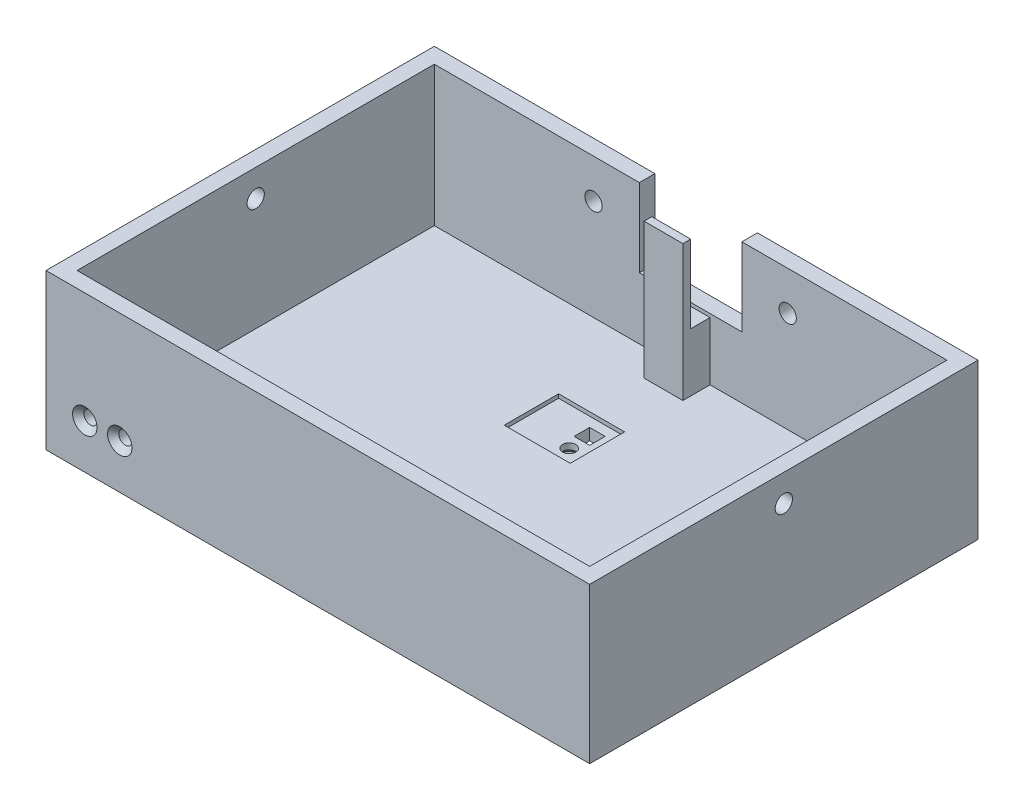
from build123d import *

# Parameters (mm, degrees)
SKETCH_1_W                  = 140
SKETCH_1_H                  = 100
SKETCH_1_W_2                = 132
SKETCH_1_H_2                = 92
EXTRUDE_2_DEPTH             = 4
EXTRUDE_3_DEPTH             = 2
EXTRUDE_START               = 4
SKETCH_1_6_W                = 140
SKETCH_1_6_H                = 100
SKETCH_1_6_W_2              = 132
SKETCH_1_6_H_2              = 92
EXTRUDE_4_DEPTH             = 36
HOLE_WIZARD_M31_D           = 3.4
HOLE_WIZARD_M31_DEPTH       = 4
HOLE_WIZARD_M31_CSINK_D     = 6.3
HOLE_WIZARD_M31_CSINK_ANGLE = 90
CUT_EXTRUDE_1_REACH         = 155.948
SKETCH_6_R                  = 2.225
CUT_EXTRUDE_3_REACH         = 130.452
SKETCH_7_W                  = 26.4
SKETCH_7_H                  = 20.1
CUT_EXTRUDE_6_REACH         = 130.452
SKETCH_7_9_R                = 2.225
HOLE_WIZARD_M33_D           = 3.4
HOLE_WIZARD_M33_CSINK_D     = 6.3
HOLE_WIZARD_M33_CSINK_ANGLE = 90
CUT_EXTRUDE_8_REACH         = 96.868
SKETCH_15_W                 = 4
SKETCH_15_H                 = 4
CUT_EXTRUDE_9_REACH         = 99.868
CUT_EXTRUDE_START           = -3
SKETCH_15_4_W               = 17
SKETCH_15_4_H               = 14
SKETCH_15_4_W_2             = 4
SKETCH_15_4_H_2             = 4
EXTRUDE_START_2             = -4
SKETCH_20_W                 = 10
SKETCH_20_H                 = 5
SKETCH_20_H_2               = 2
EXTRUDE_7_DEPTH             = 15
EXTRUDE_START_3             = -39
SKETCH_20_3_W               = 10
SKETCH_20_3_H               = 2
EXTRUDE_8_DEPTH             = 20
SKETCH_21_W                 = 0.664850428
SKETCH_21_H                 = 3.704166666
CUT_EXTRUDE_10_DEPTH        = 1


with BuildPart() as part:
    # Эскиз1 → Бобышка-Вытянуть2 (new body)
    with BuildSketch(Plane(origin=(0, 0, 0), x_dir=(1, 0, 0), z_dir=(0, 1, 0))):
        Rectangle(SKETCH_1_W, SKETCH_1_H)
        Rectangle(SKETCH_1_W_2, SKETCH_1_H_2, mode=Mode.SUBTRACT)
        Polygon((66, -46), (66, 46), (-66, 46), (-66, -46), (-63, -46), (-63, -44.5), (-59.5, -44.5), (-59.5, -41.9), (-51.5, -41.9), (-51.5, -44.5), (-48, -44.5), (-48, -46), align=None)
    extrude(amount=EXTRUDE_2_DEPTH)

    # Эскиз1<5> → Бобышка-Вытянуть3 (add)
    with BuildSketch(Plane(origin=(0, 0, 0), x_dir=(1, 0, 0), z_dir=(0, 1, 0))):
        Polygon((-63, -46), (-48, -46), (-48, -44.5), (-51.5, -44.5), (-51.5, -44.6), (-59.5, -44.6), (-59.5, -44.5), (-63, -44.5), align=None)
    extrude(amount=EXTRUDE_3_DEPTH)

    # Эскиз1<6> → Бобышка-Вытянуть4 (add)
    with BuildSketch(Plane(origin=(0, 0, 0), x_dir=(1, 0, 0), z_dir=(0, 1, 0)).offset(EXTRUDE_START)):
        Rectangle(SKETCH_1_6_W, SKETCH_1_6_H)
        Rectangle(SKETCH_1_6_W_2, SKETCH_1_6_H_2, mode=Mode.SUBTRACT)
    extrude(amount=EXTRUDE_4_DEPTH)

    # Зенковка для винта с потайной головкой M31
    with Locations(Plane(origin=(-51, 11.5, 50), x_dir=(1, 0, 0), z_dir=(0, 0, 1))):
        with Locations((0, 0), (-9, 0)):
            CounterSinkHole(HOLE_WIZARD_M31_D / 2, HOLE_WIZARD_M31_CSINK_D / 2, depth=HOLE_WIZARD_M31_DEPTH, counter_sink_angle=HOLE_WIZARD_M31_CSINK_ANGLE)

    # Эскиз6 → Вырез-Вытянуть1 (cut, up to next)
    with BuildSketch(Plane(origin=(70, 0, 0), x_dir=(0, 0, -1), z_dir=(1, 0, 0)), mode=Mode.PRIVATE) as cut_extrude_1_sk1:
        with Locations((0, 33)):
            Circle(SKETCH_6_R)
    cut_extrude_1_tool1 = extrude(cut_extrude_1_sk1.sketch, amount=-CUT_EXTRUDE_1_REACH, mode=Mode.PRIVATE) & part.part
    cut_extrude_1 = cut_extrude_1_tool1.solids().sort_by_distance((70, 33, 0))[0]
    add(cut_extrude_1, mode=Mode.SUBTRACT)

    # Зеркальное отражение1: Вырез-Вытянуть1 across plane
    add(cut_extrude_1.mirror(Plane(origin=(0, 0, 0), x_dir=(0, 0, 1), z_dir=(1, 0, 0))), mode=Mode.SUBTRACT)

    # Эскиз7 → Вырез-Вытянуть3 (cut, up to next)
    with BuildSketch(Plane(origin=(0, 0, -50), x_dir=(-1, 0, 0), z_dir=(0, 0, -1)), mode=Mode.PRIVATE) as cut_extrude_3_sk1:
        with Locations((0, 29.95)):
            Rectangle(SKETCH_7_W, SKETCH_7_H)
    cut_extrude_3_tool1 = extrude(cut_extrude_3_sk1.sketch, amount=-CUT_EXTRUDE_3_REACH, mode=Mode.PRIVATE) & part.part
    add(cut_extrude_3_tool1.solids().sort_by_distance((0, 29.95, -50))[0], mode=Mode.SUBTRACT)

    # Эскиз7<9> → Вырез-Вытянуть6 (cut, up to next)
    with BuildSketch(Plane(origin=(0, 0, -50), x_dir=(-1, 0, 0), z_dir=(0, 0, -1)), mode=Mode.PRIVATE) as cut_extrude_6_sk1:
        with Locations((-25, 29.95)):
            Circle(SKETCH_7_9_R)
    cut_extrude_6_tool1 = extrude(cut_extrude_6_sk1.sketch, amount=-CUT_EXTRUDE_6_REACH, mode=Mode.PRIVATE) & part.part
    # Эскиз7<9> → Вырез-Вытянуть6 (cut, up to next)
    with BuildSketch(Plane(origin=(0, 0, -50), x_dir=(-1, 0, 0), z_dir=(0, 0, -1)), mode=Mode.PRIVATE) as cut_extrude_6_sk2:
        with Locations((25, 29.95)):
            Circle(SKETCH_7_9_R)
    cut_extrude_6_tool2 = extrude(cut_extrude_6_sk2.sketch, amount=-CUT_EXTRUDE_6_REACH, mode=Mode.PRIVATE) & part.part
    add(cut_extrude_6_tool1.solids().sort_by_distance((25, 29.95, -50))[0], mode=Mode.SUBTRACT)
    add(cut_extrude_6_tool2.solids().sort_by_distance((-25, 29.95, -50))[0], mode=Mode.SUBTRACT)

    # Зенковка для винта с потайной головкой M33 (through all)
    with Locations(Plane(origin=(0, 0, -14.7), x_dir=(0, 0, -1), z_dir=(0, -1, 0))):
        with Locations((0, 0)):
            CounterSinkHole(HOLE_WIZARD_M33_D / 2, HOLE_WIZARD_M33_CSINK_D / 2, counter_sink_angle=HOLE_WIZARD_M33_CSINK_ANGLE)

    # Эскиз15 → Вырез-Вытянуть8 (cut, up to next)
    with BuildSketch(Plane.XZ, mode=Mode.PRIVATE) as cut_extrude_8_sk1:
        with Locations((0, -20)):
            Rectangle(SKETCH_15_W, SKETCH_15_H)
    cut_extrude_8_tool1 = extrude(cut_extrude_8_sk1.sketch, amount=-CUT_EXTRUDE_8_REACH, mode=Mode.PRIVATE) & part.part
    add(cut_extrude_8_tool1.solids().sort_by_distance((0, 0, -20))[0], mode=Mode.SUBTRACT)

    # Эскиз15<4> → Вырез-Вытянуть9 (cut, up to next)
    with BuildSketch(Plane.XZ.offset(CUT_EXTRUDE_START), mode=Mode.PRIVATE) as cut_extrude_9_sk1:
        with Locations((-4, -17.5)):
            Rectangle(SKETCH_15_4_W, SKETCH_15_4_H)
        with Locations((0, -20)):
            Rectangle(SKETCH_15_4_W_2, SKETCH_15_4_H_2, mode=Mode.SUBTRACT)
    cut_extrude_9_tool1 = extrude(cut_extrude_9_sk1.sketch, amount=-CUT_EXTRUDE_9_REACH, mode=Mode.PRIVATE) & part.part
    add(cut_extrude_9_tool1.solids().sort_by_distance((-4.288288, 3, -17.31982))[0], mode=Mode.SUBTRACT)

    # Эскиз20 → Бобышка-Вытянуть7 (add)
    with BuildSketch(Plane.XZ.offset(EXTRUDE_START_2)):
        with Locations((0, -43.5)):
            Rectangle(SKETCH_20_W, SKETCH_20_H)
        with Locations((0, -40)):
            Rectangle(SKETCH_20_W, SKETCH_20_H_2)
    extrude(amount=-EXTRUDE_7_DEPTH)

    # Эскиз20<3> → Бобышка-Вытянуть8 (add)
    with BuildSketch(Plane.XZ.offset(EXTRUDE_START_3)):
        with Locations((0, -40)):
            Rectangle(SKETCH_20_3_W, SKETCH_20_3_H)
    extrude(amount=EXTRUDE_8_DEPTH)

    # Эскиз21 → Вырез-Вытянуть10 (cut)
    with BuildSketch(Plane.XZ):
        Polygon((-7.360844017, 26.295833333), (-8.100638522, 26.295833333), (-8.761778846, 27.595111345), (-9.422919171, 26.295833333), (-10.162713675, 26.295833333), (-9.09420406, 28.395751536), (-9.09420406, 30), (-8.429353632, 30), (-8.429353632, 28.395751536), align=None)
        with BuildLine():
            Line((-4.67769765, 30), (-4.67769765, 26.295833333))
            Line((-4.67769765, 26.295833333), (-5.271314103, 26.295833333))
            add(Edge.make_bspline(
                [(-5.271314103, 26.295833333), (-5.31287104, 26.29582766), (-5.393282926, 26.295816683), (-5.509295092, 26.299903172), (-5.616644377, 26.305119252), (-5.715461788, 26.311150817), (-5.805710741, 26.321160915), (-5.887453392, 26.331933671), (-5.960386991, 26.344839118), (-6.005477322, 26.356423188), (-6.026691039, 26.361873164)],
                knots=[0, 0, 0, 0, 1.311970222, 2.538637508, 3.664491357, 4.705491327, 5.663608299, 6.530571107, 7.308675535, 8, 8, 8, 8], degree=3))
            add(Edge.make_bspline(
                [(-6.026691039, 26.361873164), (-6.054546615, 26.369560182), (-6.109208197, 26.384644579), (-6.187505155, 26.415102656), (-6.261764836, 26.448979565), (-6.331971001, 26.48755156), (-6.397293339, 26.531538006), (-6.458627281, 26.580099943), (-6.515687524, 26.633253783), (-6.567564548, 26.691314468), (-6.614388963, 26.752752651), (-6.655239972, 26.817596967), (-6.690526167, 26.884819689), (-6.717620988, 26.955580973), (-6.740373771, 27.028032846), (-6.755595868, 27.103646953), (-6.765809559, 27.181771929), (-6.766750122, 27.234950154), (-6.767227564, 27.261944111)],
                knots=[0, 0, 0, 0, 1.099879008, 2.158315707, 3.195196496, 4.207130292, 5.205157476, 6.190838564, 7.183874245, 8.171129509, 9.152705923, 10.122275948, 11.08707516, 12.038677937, 13.004120747, 13.975884785, 14.972532894, 16, 16, 16, 16], degree=3))
            add(Edge.make_bspline(
                [(-6.767227564, 27.261944111), (-6.76606929, 27.296642989), (-6.763788001, 27.364984441), (-6.746281055, 27.464900878), (-6.718067585, 27.559857826), (-6.67819946, 27.650677442), (-6.624678653, 27.737222193), (-6.557936859, 27.821133851), (-6.476313973, 27.901266692), (-6.414743342, 27.950351077), (-6.382860911, 27.975767895)],
                knots=[0, 0, 0, 0, 0.986462413, 1.942894939, 2.875435142, 3.798266677, 4.755009598, 5.761362919, 6.840791609, 8, 8, 8, 8], degree=3))
            add(Edge.make_bspline(
                [(-6.382860911, 27.975767895), (-6.408979822, 27.989097155), (-6.460191781, 28.015232146), (-6.532852683, 28.058239537), (-6.600297973, 28.103797407), (-6.662059563, 28.151835509), (-6.719599834, 28.201400191), (-6.769346127, 28.255527376), (-6.816213212, 28.310039174), (-6.856337282, 28.368448582), (-6.891028514, 28.42950758), (-6.921804296, 28.492525813), (-6.946942144, 28.558756422), (-6.968581336, 28.627252077), (-6.984979225, 28.698720449), (-6.995584602, 28.772715956), (-7.003720801, 28.849195216), (-7.004352804, 28.901291794), (-7.004674145, 28.927780282)],
                knots=[0, 0, 0, 0, 1.164301211, 2.282872552, 3.350830854, 4.394111106, 5.389302619, 6.362088852, 7.310365691, 8.24222091, 9.170601078, 10.097577168, 11.024240953, 11.981127157, 12.948542686, 13.932080445, 14.948567018, 16, 16, 16, 16], degree=3))
            add(Edge.make_bspline(
                [(-7.004674145, 28.927780282), (-7.002692802, 28.978397696), (-6.998780658, 29.078341299), (-6.96712433, 29.224518762), (-6.916596092, 29.36381475), (-6.84574944, 29.493996255), (-6.759425249, 29.61275297), (-6.660581223, 29.717639041), (-6.549120308, 29.805474765), (-6.446974469, 29.865364426), (-6.358155382, 29.905297616), (-6.284285354, 29.929765961), (-6.20499898, 29.952445355), (-6.119408383, 29.970015998), (-6.027940433, 29.983108035), (-5.930636934, 29.992646338), (-5.827162295, 29.99866195), (-5.756109363, 29.999544966), (-5.719494525, 30)],
                knots=[0, 0, 0, 0, 1.284225818, 2.535691644, 3.779474941, 5.035581115, 6.285533147, 7.498311102, 8.683187976, 9.876672238, 10.49522506, 11.152635743, 11.850557634, 12.588370465, 13.369094102, 14.195874568, 15.07030211, 16, 16, 16, 16], degree=3))
            Line((-5.719494525, 30), (-4.67769765, 30))
        make_face()
        with BuildLine():
            Line((-5.342548077, 26.960683761), (-5.342548077, 27.768002137))
            Line((-5.342548077, 27.768002137), (-5.519148972, 27.768002137))
            add(Edge.make_bspline(
                [(-5.519148972, 27.768002137), (-5.543150918, 27.767793787), (-5.589485222, 27.767391581), (-5.656405391, 27.762174814), (-5.718647736, 27.753340305), (-5.776129913, 27.740752532), (-5.829187703, 27.725499305), (-5.877192725, 27.70609866), (-5.920300863, 27.682950654), (-5.97109283, 27.649311019), (-6.023411598, 27.597796057), (-6.070260271, 27.525078967), (-6.097716924, 27.440911558), (-6.100790162, 27.381609366), (-6.102377137, 27.350986579)],
                knots=[0, 0, 0, 0, 1.06517797, 2.056261606, 2.976983468, 3.853439442, 4.666321732, 5.424739265, 6.146762548, 6.834937974, 8.123729748, 9.372478121, 10.64318598, 12, 12, 12, 12], degree=3))
            add(Edge.make_bspline(
                [(-6.102377137, 27.350986579), (-6.101107736, 27.322301724), (-6.0986534, 27.266840711), (-6.07098899, 27.188915267), (-6.02789325, 27.120216444), (-5.977780501, 27.072519042), (-5.92999461, 27.040450445), (-5.888860674, 27.019067359), (-5.843656126, 27.000080932), (-5.793272027, 26.986822794), (-5.739218145, 26.974378655), (-5.680330231, 26.966811946), (-5.617204196, 26.961226635), (-5.57357826, 26.9608686), (-5.551055856, 26.960683761)],
                knots=[0, 0, 0, 0, 1.347812291, 2.605940898, 3.848830773, 5.144272192, 5.83350599, 6.558918059, 7.32804622, 8.140548749, 9.012446266, 9.943019774, 10.938059685, 12, 12, 12, 12], degree=3))
            Line((-5.551055856, 26.960683761), (-5.342548077, 26.960683761))
        make_face(mode=Mode.SUBTRACT)
        with BuildLine():
            Line((-5.342548077, 28.385363248), (-5.342548077, 29.335149573))
            Line((-5.342548077, 29.335149573), (-5.533989383, 29.335149573))
            add(Edge.make_bspline(
                [(-5.533989383, 29.335149573), (-5.571836642, 29.334929454), (-5.644602721, 29.334506248), (-5.748854794, 29.329534528), (-5.843594627, 29.320313304), (-5.928844514, 29.309547079), (-6.003906665, 29.292523899), (-6.070151968, 29.274824174), (-6.1264325, 29.252057352), (-6.17370873, 29.225655995), (-6.213247633, 29.195791329), (-6.247485595, 29.163470084), (-6.276042616, 29.127354439), (-6.299008818, 29.08824331), (-6.31830134, 29.046497592), (-6.330119516, 29.000731595), (-6.339075358, 28.952368581), (-6.339570425, 28.918921985), (-6.339823718, 28.901809562)],
                knots=[0, 0, 0, 0, 1.753677247, 3.371663338, 4.833688836, 6.164395063, 7.349095089, 8.3975697, 9.338276771, 10.154261968, 10.899224605, 11.628775934, 12.330426574, 13.024264642, 13.727131073, 14.452891561, 15.208446408, 16, 16, 16, 16], degree=3))
            add(Edge.make_bspline(
                [(-6.339823718, 28.901809562), (-6.339267862, 28.88224015), (-6.338185204, 28.844124201), (-6.329314979, 28.78842355), (-6.31326656, 28.73638578), (-6.292737226, 28.686661361), (-6.265021063, 28.640606417), (-6.231164445, 28.597914337), (-6.191468328, 28.558459282), (-6.145807334, 28.521643116), (-6.092791868, 28.488572661), (-6.031202431, 28.461825413), (-5.962630199, 28.437695864), (-5.885732735, 28.419043462), (-5.801112201, 28.403045041), (-5.708035099, 28.393532236), (-5.607311669, 28.386443148), (-5.537466849, 28.385731394), (-5.501340478, 28.385363248)],
                knots=[0, 0, 0, 0, 0.844862234, 1.645564352, 2.426138401, 3.19188377, 3.963047654, 4.738710309, 5.53926994, 6.37496817, 7.267116735, 8.227971149, 9.268346748, 10.402975021, 11.641070045, 12.984514716, 14.440277492, 16, 16, 16, 16], degree=3))
            Line((-5.501340478, 28.385363248), (-5.342548077, 28.385363248))
        make_face(mode=Mode.SUBTRACT)
        Polygon((-0.593616453, 26.295833333), (-2.588167735, 26.295833333), (-2.588167735, 26.960683761), (-1.25846688, 26.960683761), (-1.25846688, 27.673023504), (-2.588167735, 27.673023504), (-2.588167735, 28.337873932), (-1.25846688, 28.337873932), (-1.25846688, 29.335149573), (-2.588167735, 29.335149573), (-2.588167735, 30), (-0.593616453, 30), align=None)
        with BuildLine():
            Line((3.015571581, 26.295833333), (2.177830362, 26.295833333))
            add(Edge.make_bspline(
                [(2.177830362, 26.295833333), (2.112517208, 26.296279346), (1.986266142, 26.297141494), (1.803379182, 26.30722713), (1.633190412, 26.322037433), (1.476084825, 26.344703935), (1.331496675, 26.371011955), (1.200493246, 26.406243982), (1.082008378, 26.446675766), (0.974798578, 26.493784373), (0.877193779, 26.549031863), (0.785172007, 26.611100127), (0.697670919, 26.680920335), (0.614205601, 26.758655019), (0.534572647, 26.843787324), (0.460641374, 26.938031461), (0.390041599, 27.03894638), (0.323918809, 27.146882332), (0.265061267, 27.261626225), (0.212671457, 27.381372071), (0.169021282, 27.506197699), (0.13347976, 27.635930755), (0.105168974, 27.770195435), (0.085355478, 27.909247561), (0.073107843, 28.052962573), (0.07186533, 28.150365134), (0.071233974, 28.199858106)],
                knots=[0, 0, 0, 0, 1.44349102, 2.790284463, 4.047513061, 5.218094321, 6.297837468, 7.293772999, 8.213586047, 9.062895527, 9.878013142, 10.689252941, 11.514048747, 12.349645483, 13.208421871, 14.087867281, 14.994836234, 15.929653487, 16.883274053, 17.843080533, 18.816554169, 19.803369425, 20.81449504, 21.847452076, 22.906230055, 24, 24, 24, 24], degree=3))
            add(Edge.make_bspline(
                [(0.071233974, 28.199858106), (0.072887037, 28.269696003), (0.076141188, 28.407175991), (0.103555301, 28.608925044), (0.147885975, 28.802326415), (0.210244162, 28.985844916), (0.287464039, 29.157926595), (0.379944374, 29.315124356), (0.485028616, 29.457758629), (0.603649263, 29.583462816), (0.731883678, 29.69216878), (0.865667065, 29.784182979), (1.004879735, 29.858041143), (1.127803931, 29.904163618), (1.234694759, 29.933151783), (1.328404927, 29.949991966), (1.435055199, 29.965610546), (1.555047536, 29.979035128), (1.688737769, 29.988228315), (1.83571191, 29.994576859), (1.996005557, 29.999294231), (2.107334607, 29.999758579), (2.165216012, 30)],
                knots=[0, 0, 0, 0, 1.315347898, 2.589339334, 3.828278609, 5.048487211, 6.235212834, 7.375728391, 8.47833097, 9.56625089, 10.624194351, 11.640157642, 12.619895326, 13.585848527, 14.106971868, 14.704705962, 15.37825295, 16.137840974, 16.978850452, 17.902510282, 18.909488129, 20, 20, 20, 20], degree=3))
            Line((2.165216012, 30), (3.015571581, 30))
            Line((3.015571581, 30), (3.015571581, 26.295833333))
        make_face()
        with BuildLine():
            Line((2.350721154, 26.960683761), (2.350721154, 29.335149573))
            Line((2.350721154, 29.335149573), (2.003455529, 29.335149573))
            add(Edge.make_bspline(
                [(2.003455529, 29.335149573), (1.962143416, 29.334949523), (1.882698503, 29.334564818), (1.767857898, 29.329279022), (1.661875638, 29.320695518), (1.564612902, 29.307999222), (1.47584609, 29.292722328), (1.395898998, 29.273826825), (1.324614054, 29.250848453), (1.26140341, 29.22376821), (1.203693487, 29.192850105), (1.150229912, 29.156747291), (1.098631039, 29.116625617), (1.049850562, 29.071341384), (1.003706716, 29.021484388), (0.96047237, 28.966800313), (0.919567981, 28.907455897), (0.882054014, 28.843135016), (0.847741196, 28.774526831), (0.817426711, 28.702257198), (0.791835736, 28.625932135), (0.772401883, 28.545585428), (0.755846802, 28.461715662), (0.743892763, 28.37378358), (0.737380162, 28.282076463), (0.736520533, 28.219655142), (0.736084402, 28.187985777)],
                knots=[0, 0, 0, 0, 1.502729547, 2.8898115, 4.181010027, 5.369596896, 6.45687185, 7.456390247, 8.355533714, 9.177830239, 9.954819978, 10.733423081, 11.521791071, 12.330436719, 13.151797389, 13.990712567, 14.864234656, 15.771624029, 16.697123225, 17.652960569, 18.620374037, 19.622036587, 20.657870943, 21.729319508, 22.8479736, 24, 24, 24, 24], degree=3))
            add(Edge.make_bspline(
                [(0.736084402, 28.187985777), (0.736967187, 28.13945709), (0.73868855, 28.044829909), (0.75539277, 27.907021755), (0.782308144, 27.777417158), (0.821516404, 27.656349058), (0.869732311, 27.543047772), (0.931039844, 27.438973329), (1.001714565, 27.342419836), (1.057634518, 27.285788843), (1.085576088, 27.257491987)],
                knots=[0, 0, 0, 0, 1.138242922, 2.219485503, 3.251901297, 4.239342788, 5.201071, 6.134757343, 7.067992642, 8, 8, 8, 8], degree=3))
            add(Edge.make_bspline(
                [(1.085576088, 27.257491987), (1.113126827, 27.233378423), (1.169396092, 27.184129198), (1.268186429, 27.125116032), (1.377048264, 27.073267181), (1.49847203, 27.032156824), (1.631284219, 26.999645002), (1.776275864, 26.977222393), (1.932670503, 26.962813862), (2.041017064, 26.961409006), (2.09695012, 26.960683761)],
                knots=[0, 0, 0, 0, 0.813307809, 1.661089106, 2.549956539, 3.493439533, 4.508053171, 5.589449661, 6.755572447, 8, 8, 8, 8], degree=3))
            Line((2.09695012, 26.960683761), (2.350721154, 26.960683761))
        make_face(mode=Mode.SUBTRACT)
        Polygon((5.67423127, 26.295833333), (5.057612179, 26.295833333), (3.561698718, 30), (4.2718124, 30), (4.55971638, 29.24017094), (6.173611111, 29.24017094), (6.461515091, 30), (7.170886752, 30), align=None)
        Polygon((5.366292735, 27.289398872), (5.921324119, 28.575320513), (4.811261351, 28.575320513), align=None, mode=Mode.SUBTRACT)
        Polygon((11.128082432, 26.295833333), (10.438003305, 26.295833333), (9.59284188, 28.879548945), (8.741744291, 26.295833333), (8.058343349, 26.295833333), (7.432077991, 30), (8.105090645, 30), (8.500587607, 27.660409155), (9.270804955, 30), (9.919330929, 30), (10.685096154, 27.660409155), (11.079851095, 30), (11.753605769, 30), align=None)
        with Locations((-24.789423077, 35.369017094)):
            Rectangle(SKETCH_21_W, SKETCH_21_H)
        Polygon((-21.892574786, 33.516933761), (-23.887126068, 33.516933761), (-23.887126068, 34.181784188), (-22.557425214, 34.181784188), (-22.557425214, 34.894123932), (-23.887126068, 34.894123932), (-23.887126068, 35.558974359), (-22.557425214, 35.558974359), (-22.557425214, 36.55625), (-23.887126068, 36.55625), (-23.887126068, 37.221100427), (-21.892574786, 37.221100427), align=None)
        Polygon((-17.579209235, 33.516933761), (-18.269288361, 33.516933761), (-19.114449786, 36.100649372), (-19.965547376, 33.516933761), (-20.648948317, 33.516933761), (-21.275213675, 37.221100427), (-20.602201022, 37.221100427), (-20.20670406, 34.881509582), (-19.436486712, 37.221100427), (-18.787960737, 37.221100427), (-18.022195513, 34.881509582), (-17.627440572, 37.221100427), (-16.953685897, 37.221100427), align=None)
        with BuildLine():
            add(Edge.make_bspline(
                [(-14.705363582, 33.421955128), (-14.76976538, 33.423621928), (-14.896909117, 33.426912568), (-15.083886107, 33.454363303), (-15.264094619, 33.499038862), (-15.437560483, 33.561398748), (-15.603692097, 33.642160392), (-15.763099871, 33.740220734), (-15.915346963, 33.856411855), (-16.058658326, 33.989075704), (-16.190071338, 34.134139472), (-16.305584868, 34.288798347), (-16.403641213, 34.451455541), (-16.483233785, 34.622142746), (-16.545389843, 34.800625505), (-16.588587573, 34.986971553), (-16.616440445, 35.180942266), (-16.619636403, 35.313021049), (-16.621260684, 35.380147403)],
                knots=[0, 0, 0, 0, 1.014151002, 2.002163778, 2.969868608, 3.93493411, 4.9003771, 5.874719092, 6.87846472, 7.912488755, 8.947011879, 9.957751389, 10.948740761, 11.933621513, 12.919426746, 13.920294397, 14.943031967, 16, 16, 16, 16], degree=3))
            add(Edge.make_bspline(
                [(-16.621260684, 35.380147403), (-16.619530349, 35.446517269), (-16.616120669, 35.57730122), (-16.589728018, 35.769486236), (-16.545779498, 35.953829441), (-16.484821734, 36.130393858), (-16.406620854, 36.29918238), (-16.310062019, 36.459647309), (-16.195779624, 36.61211835), (-16.066108133, 36.755661408), (-15.924231793, 36.886803311), (-15.773065117, 37.001929792), (-15.614012522, 37.09876179), (-15.448090221, 37.179134426), (-15.273732924, 37.239532176), (-15.092873717, 37.28474007), (-14.903999662, 37.310881764), (-14.775686854, 37.314329205), (-14.710557726, 37.31607906)],
                knots=[0, 0, 0, 0, 1.051517626, 2.07204922, 3.067438659, 4.05042616, 5.027204762, 6.009981242, 7.012629434, 8.042243656, 9.071350414, 10.070091277, 11.048190212, 12.017682766, 12.985867053, 13.966945899, 14.968060614, 16, 16, 16, 16], degree=3))
            add(Edge.make_bspline(
                [(-14.710557726, 37.31607906), (-14.642435195, 37.314527756), (-14.508583734, 37.311479655), (-14.312642895, 37.282738127), (-14.125182194, 37.238917841), (-13.946715278, 37.17547661), (-13.777380883, 37.093043563), (-13.616419618, 36.99351195), (-13.465042054, 36.87495918), (-13.323752777, 36.740961007), (-13.195759261, 36.594299591), (-13.082775979, 36.439374679), (-12.987473054, 36.277357875), (-12.909845588, 36.108176448), (-12.848647277, 35.932881011), (-12.805478806, 35.750404179), (-12.779978163, 35.56118354), (-12.776426072, 35.432661101), (-12.774626068, 35.367533053)],
                knots=[0, 0, 0, 0, 1.067953136, 2.098381936, 3.099641766, 4.083805132, 5.062469929, 6.048665414, 7.046702845, 8.073106546, 9.098695993, 10.09591865, 11.076726721, 12.041940862, 13.011263376, 13.984305721, 14.978557872, 16, 16, 16, 16], degree=3))
            add(Edge.make_bspline(
                [(-12.774626068, 35.367533053), (-12.775198807, 35.323720211), (-12.776337033, 35.2366493), (-12.789747111, 35.10758116), (-12.809635896, 34.981217252), (-12.836863166, 34.857319954), (-12.873547352, 34.736208555), (-12.918134, 34.61757756), (-12.970091499, 34.501427624), (-13.030007529, 34.388809159), (-13.097784513, 34.281069585), (-13.170152046, 34.177267897), (-13.249881955, 34.080129095), (-13.335328582, 33.988598012), (-13.426826612, 33.903093059), (-13.524535401, 33.823322272), (-13.628301155, 33.749489113), (-13.737001511, 33.680983463), (-13.850264629, 33.620983157), (-13.965395767, 33.566597273), (-14.08350017, 33.522501213), (-14.20372032, 33.485979468), (-14.325779821, 33.456669284), (-14.450621079, 33.43718051), (-14.577190461, 33.423664491), (-14.662537815, 33.422526268), (-14.705363582, 33.421955128)],
                knots=[0, 0, 0, 0, 1.034641744, 2.056182551, 3.061960284, 4.05571729, 5.050247014, 6.048716841, 7.047801973, 8.054190544, 9.059424999, 10.053182006, 11.041513076, 12.025412457, 13.009311837, 13.997642908, 15.002928308, 16.016213968, 17.030509951, 18.02913364, 19.022134519, 20.005478534, 20.996155877, 21.984625117, 22.988721131, 24, 24, 24, 24], degree=3))
        make_face()
        with BuildLine():
            add(Edge.make_bspline(
                [(-14.694975294, 34.086805556), (-14.65163311, 34.087968525), (-14.566092984, 34.090263762), (-14.440621161, 34.107750318), (-14.320163918, 34.135678445), (-14.205388349, 34.176131607), (-14.0957994, 34.227619602), (-13.991193856, 34.289956296), (-13.893054206, 34.365308271), (-13.79994102, 34.449540014), (-13.71611224, 34.543781234), (-13.640738811, 34.643676397), (-13.579796335, 34.75162915), (-13.527394505, 34.864083821), (-13.488687649, 34.983884269), (-13.459216415, 35.109086142), (-13.443164433, 35.240974728), (-13.440723322, 35.330639804), (-13.439476496, 35.3764373)],
                knots=[0, 0, 0, 0, 1.033668485, 2.040047952, 3.016132939, 3.979056467, 4.937231767, 5.900589077, 6.877725736, 7.88429546, 8.891280164, 9.882584218, 10.863295226, 11.842887319, 12.837417301, 13.860812229, 14.907384602, 16, 16, 16, 16], degree=3))
            add(Edge.make_bspline(
                [(-13.439476496, 35.3764373), (-13.440992074, 35.427205361), (-13.443962357, 35.526702348), (-13.464557583, 35.671923679), (-13.500644433, 35.808913024), (-13.54994342, 35.938128658), (-13.615475835, 36.058211804), (-13.693854083, 36.17061827), (-13.787040584, 36.274650631), (-13.85870455, 36.335439662), (-13.895077123, 36.366292735)],
                knots=[0, 0, 0, 0, 1.078343132, 2.113373867, 3.107373148, 4.082093053, 5.043582658, 6.005574554, 6.987742499, 8, 8, 8, 8], degree=3))
            add(Edge.make_bspline(
                [(-13.895077123, 36.366292735), (-13.924881143, 36.389082186), (-13.983817693, 36.434147638), (-14.077893258, 36.491908259), (-14.174772566, 36.541414873), (-14.275186692, 36.581415632), (-14.378923567, 36.612879556), (-14.485968966, 36.634913225), (-14.596171214, 36.648741258), (-14.670695139, 36.65039397), (-14.708331664, 36.651228632)],
                knots=[0, 0, 0, 0, 1.023928204, 2.024787132, 3.009472467, 3.9914905, 4.972207045, 5.96565515, 6.972602802, 8, 8, 8, 8], degree=3))
            add(Edge.make_bspline(
                [(-14.708331664, 36.651228632), (-14.750927753, 36.650054138), (-14.834736898, 36.647743284), (-14.957884769, 36.630495759), (-15.075809444, 36.601178982), (-15.189603962, 36.561367862), (-15.297744529, 36.508014065), (-15.401917515, 36.444660522), (-15.500881357, 36.369331374), (-15.593429624, 36.28297692), (-15.678245163, 36.188731256), (-15.753283311, 36.08829577), (-15.815427269, 35.981666554), (-15.867263239, 35.870267945), (-15.907649232, 35.753212974), (-15.935287587, 35.630492815), (-15.953050228, 35.502602587), (-15.955276241, 35.41557718), (-15.956410256, 35.371243156)],
                knots=[0, 0, 0, 0, 1.026350473, 2.019376834, 2.989435443, 3.95094063, 4.91865229, 5.889827372, 6.885283771, 7.910196595, 8.935871797, 9.9372888, 10.925850568, 11.904605667, 12.894245083, 13.903507864, 14.931967858, 16, 16, 16, 16], degree=3))
            add(Edge.make_bspline(
                [(-15.956410256, 35.371243156), (-15.955241397, 35.327162246), (-15.952940676, 35.240395697), (-15.935596497, 35.112860252), (-15.906762389, 34.9908144), (-15.866010578, 34.873943537), (-15.815242302, 34.761634101), (-15.751468895, 34.654860841), (-15.676072678, 34.553716135), (-15.590431958, 34.458801301), (-15.49723263, 34.371574801), (-15.397169797, 34.295879545), (-15.293048117, 34.230102387), (-15.182477277, 34.178575311), (-15.06771979, 34.137523774), (-14.948075311, 34.107292839), (-14.823090705, 34.090386601), (-14.738061092, 34.088009878), (-14.694975294, 34.086805556)],
                knots=[0, 0, 0, 0, 1.055040155, 2.076685641, 3.074845078, 4.052329834, 5.035358467, 6.020382375, 7.023447318, 8.050688466, 9.077178457, 10.074336316, 11.0503314, 12.019748348, 12.988025369, 13.964577102, 14.968620271, 16, 16, 16, 16], degree=3))
        make_face(mode=Mode.SUBTRACT)
        Polygon((-10.495138889, 33.516933761), (-12.299732906, 33.516933761), (-12.299732906, 34.181784188), (-11.159989316, 34.181784188), (-11.159989316, 34.894123932), (-12.299732906, 34.894123932), (-12.299732906, 35.558974359), (-11.159989316, 35.558974359), (-11.159989316, 37.221100427), (-10.495138889, 37.221100427), align=None)
        with Locations((-9.307905983, 35.369017094)):
            Rectangle(SKETCH_21_W, SKETCH_21_H)
        Polygon((-6.553525641, 33.516933761), (-8.548076923, 33.516933761), (-8.548076923, 34.181784188), (-7.883226496, 34.181784188), (-7.883226496, 37.221100427), (-7.218376068, 37.221100427), (-7.218376068, 34.181784188), (-6.553525641, 34.181784188), align=None)
        with BuildLine():
            Line((-4.331916066, 35.754867788), (-4.748931624, 36.22827691))
            Line((-4.748931624, 36.22827691), (-4.558232338, 36.400425681))
            Line((-4.558232338, 36.400425681), (-4.369759115, 36.56960637))
            Line((-4.369759115, 36.56960637), (-4.962633547, 37.221100427))
            Line((-4.962633547, 37.221100427), (-4.11450404, 37.221100427))
            Line((-4.11450404, 37.221100427), (-3.872605335, 36.970297476))
            add(Edge.make_bspline(
                [(-3.872605335, 36.970297476), (-3.824823584, 36.993973181), (-3.731173812, 37.040376342), (-3.59012685, 37.101357759), (-3.451603407, 37.152619091), (-3.315922255, 37.195714531), (-3.181994097, 37.226968032), (-3.051146983, 37.251392421), (-2.922661039, 37.266034907), (-2.837769151, 37.267746334), (-2.795933494, 37.268589744)],
                knots=[0, 0, 0, 0, 1.134846175, 2.224240057, 3.268605059, 4.277623426, 5.251861872, 6.193569972, 7.109771376, 8, 8, 8, 8], degree=3))
            add(Edge.make_bspline(
                [(-2.795933494, 37.268589744), (-2.761526026, 37.267890707), (-2.694254804, 37.266523996), (-2.595857848, 37.255455057), (-2.502585165, 37.235919093), (-2.414229797, 37.209592751), (-2.331116956, 37.174948556), (-2.252699388, 37.133562708), (-2.179760621, 37.083469128), (-2.112507044, 37.026203326), (-2.050867996, 36.963951496), (-1.99831595, 36.895613508), (-1.952158379, 36.824425645), (-1.915932013, 36.747592991), (-1.886605088, 36.666985612), (-1.867235261, 36.581682902), (-1.853615766, 36.492627103), (-1.852602225, 36.431645659), (-1.852083333, 36.400425681)],
                knots=[0, 0, 0, 0, 1.146325904, 2.24122114, 3.293472846, 4.31812184, 5.308385844, 6.289138462, 7.267533498, 8.249981455, 9.229105173, 10.180360779, 11.117770178, 12.050384985, 13.00449251, 13.970029, 14.960738752, 16, 16, 16, 16], degree=3))
            add(Edge.make_bspline(
                [(-1.852083333, 36.400425681), (-1.853958588, 36.353038567), (-1.857693425, 36.258660348), (-1.887269611, 36.119438589), (-1.933919206, 35.983957512), (-1.989794753, 35.875716832), (-2.04338222, 35.790353753), (-2.091430023, 35.725744027), (-2.14543336, 35.660371755), (-2.207045857, 35.595149943), (-2.274129221, 35.528013928), (-2.349551491, 35.461930849), (-2.430131323, 35.393894624), (-2.487537974, 35.350451535), (-2.516933761, 35.328205963)],
                knots=[0, 0, 0, 0, 1.298575957, 2.586299866, 3.886292323, 5.218034109, 5.916202773, 6.6488126, 7.424377237, 8.240272888, 9.10843449, 10.02606486, 10.989222055, 12, 12, 12, 12], degree=3))
            add(Edge.make_bspline(
                [(-2.516933761, 35.328205963), (-2.486789799, 35.289966278), (-2.428437931, 35.215942927), (-2.351393476, 35.103003213), (-2.285634756, 34.993908571), (-2.231595265, 34.888214102), (-2.189696947, 34.785714894), (-2.159607732, 34.686422268), (-2.140716331, 34.590367358), (-2.138229023, 34.527149308), (-2.137019231, 34.496400908)],
                knots=[0, 0, 0, 0, 1.254783331, 2.428975762, 3.521264868, 4.536304978, 5.485798762, 6.371253184, 7.2077997, 8, 8, 8, 8], degree=3))
            add(Edge.make_bspline(
                [(-2.137019231, 34.496400908), (-2.137746568, 34.474096711), (-2.139210139, 34.429215472), (-2.150760555, 34.362258673), (-2.16969221, 34.295488472), (-2.195560044, 34.228783949), (-2.229358574, 34.162741125), (-2.269874432, 34.096624052), (-2.318160203, 34.031000724), (-2.373030478, 33.966114606), (-2.434905213, 33.90541779), (-2.503208763, 33.851552183), (-2.578194158, 33.806825223), (-2.659205845, 33.770396509), (-2.745861055, 33.741242638), (-2.839033793, 33.721769428), (-2.937767941, 33.708449123), (-3.00587808, 33.707419134), (-3.04080028, 33.706891026)],
                knots=[0, 0, 0, 0, 0.803898129, 1.617630241, 2.442092495, 3.303311795, 4.192745454, 5.11355102, 6.096443408, 7.127633651, 8.174554725, 9.216449452, 10.256510395, 11.314202351, 12.414104221, 13.545904242, 14.741708296, 16, 16, 16, 16], degree=3))
            add(Edge.make_bspline(
                [(-3.04080028, 33.706891026), (-3.075967573, 33.707424675), (-3.144566181, 33.708465632), (-3.244065787, 33.721715057), (-3.337576594, 33.741378673), (-3.424798886, 33.769405562), (-3.505384142, 33.80628261), (-3.580521906, 33.849777441), (-3.648161585, 33.90322545), (-3.709292712, 33.963154486), (-3.763315804, 34.026968145), (-3.810469649, 34.092099365), (-3.850817871, 34.157154233), (-3.883196023, 34.222714391), (-3.910273867, 34.287526425), (-3.92757484, 34.353505045), (-3.939451022, 34.419297827), (-3.94089822, 34.463454031), (-3.941613248, 34.4852706)],
                knots=[0, 0, 0, 0, 1.276613589, 2.490209188, 3.639193385, 4.744453696, 5.809999019, 6.853188294, 7.890207437, 8.932196598, 9.958377908, 10.92346682, 11.851109371, 12.735083872, 13.577633109, 14.397160969, 15.208073967, 16, 16, 16, 16], degree=3))
            add(Edge.make_bspline(
                [(-3.941613248, 34.4852706), (-3.940380217, 34.519511989), (-3.937928421, 34.587598587), (-3.916497154, 34.688199145), (-3.884123963, 34.786956173), (-3.844410872, 34.867749035), (-3.803253851, 34.934037485), (-3.763489369, 34.990135026), (-3.714423414, 35.051116728), (-3.656981624, 35.117924754), (-3.591602805, 35.190832952), (-3.517213385, 35.269346112), (-3.434334533, 35.353951633), (-3.3750995, 35.411209014), (-3.344286692, 35.440993089)],
                knots=[0, 0, 0, 0, 1.060773976, 2.109274582, 3.176545833, 4.277732972, 4.890795241, 5.595227009, 6.408622695, 7.317144787, 8.327436618, 9.445222173, 10.671058765, 12, 12, 12, 12], degree=3))
            add(Edge.make_bspline(
                [(-3.344286692, 35.440993089), (-3.380127531, 35.482566595), (-3.448253538, 35.561589214), (-3.545471268, 35.673623204), (-3.632436444, 35.77339038), (-3.709708591, 35.860856683), (-3.776570562, 35.936657197), (-3.83489443, 35.998853547), (-3.882218753, 36.049468984), (-3.910664968, 36.078912642), (-3.923062734, 36.091745126)],
                knots=[0, 0, 0, 0, 1.51243447, 2.87482453, 4.087181207, 5.159139051, 6.090728175, 6.871952111, 7.508360801, 8, 8, 8, 8], degree=3))
            add(Edge.make_bspline(
                [(-3.923062734, 36.091745126), (-3.930955974, 36.085533912), (-3.949385096, 36.071031984), (-3.981689176, 36.04687022), (-4.020643574, 36.014426087), (-4.068443056, 35.976276278), (-4.122738975, 35.930021291), (-4.185711242, 35.878059818), (-4.255890071, 35.818571113), (-4.305675984, 35.776854748), (-4.331916066, 35.754867788)],
                knots=[0, 0, 0, 0, 0.454982147, 1.062291435, 1.826978546, 2.750907302, 3.832570326, 5.057685674, 6.44922862, 8, 8, 8, 8], degree=3))
        make_face()
        with BuildLine():
            add(Edge.make_bspline(
                [(-2.9873748, 34.952743556), (-3.010088905, 34.933684727), (-3.053714991, 34.897079188), (-3.112855887, 34.841017678), (-3.163318436, 34.786946923), (-3.203636537, 34.733727366), (-3.236128459, 34.682634124), (-3.25950791, 34.632919711), (-3.273954816, 34.584517037), (-3.275847362, 34.552634289), (-3.276762821, 34.537212039)],
                knots=[0, 0, 0, 0, 1.365108641, 2.621910227, 3.750473504, 4.766462676, 5.692471511, 6.533310132, 7.290536163, 8, 8, 8, 8], degree=3))
            add(Edge.make_bspline(
                [(-3.276762821, 34.537212039), (-3.275865302, 34.522047131), (-3.274143095, 34.492947902), (-3.262007075, 34.451147055), (-3.2406074, 34.414548646), (-3.212227166, 34.382040412), (-3.17650848, 34.356422471), (-3.135300529, 34.337297871), (-3.088862358, 34.326231074), (-3.056194244, 34.324926266), (-3.039316239, 34.324252137)],
                knots=[0, 0, 0, 0, 1.016660416, 1.95082179, 2.886895472, 3.838707486, 4.824036216, 5.811038779, 6.869071653, 8, 8, 8, 8], degree=3))
            add(Edge.make_bspline(
                [(-3.039316239, 34.324252137), (-3.023403643, 34.325139362), (-2.992053444, 34.326887329), (-2.947073113, 34.339762429), (-2.906025436, 34.36106331), (-2.870022284, 34.390041), (-2.839734174, 34.424260727), (-2.817794662, 34.462658991), (-2.804469215, 34.503950905), (-2.802744665, 34.532415747), (-2.801869658, 34.546858307)],
                knots=[0, 0, 0, 0, 1.057994133, 2.084406969, 3.085568065, 4.116326501, 5.142871292, 6.108496369, 7.040284384, 8, 8, 8, 8], degree=3))
            add(Edge.make_bspline(
                [(-2.801869658, 34.546858307), (-2.8024565, 34.561989738), (-2.803658999, 34.592995587), (-2.813323016, 34.639916144), (-2.827523908, 34.688611607), (-2.847333395, 34.739092841), (-2.874989957, 34.790258926), (-2.906510886, 34.843514386), (-2.944070783, 34.898389132), (-2.97254283, 34.934126735), (-2.9873748, 34.952743556)],
                knots=[0, 0, 0, 0, 0.798403377, 1.636010132, 2.52046941, 3.476032658, 4.492491044, 5.587786094, 6.743403203, 8, 8, 8, 8], degree=3))
        make_face(mode=Mode.SUBTRACT)
        with BuildLine():
            add(Edge.make_bspline(
                [(-3.437781283, 36.476853799), (-3.419693129, 36.459326568), (-3.381257762, 36.422083102), (-3.321025205, 36.362317554), (-3.256629586, 36.29339988), (-3.186058175, 36.217264598), (-3.110684325, 36.132626323), (-3.029628911, 36.040304522), (-2.942762805, 35.940588992), (-2.884110318, 35.870480997), (-2.853811098, 35.834263989)],
                knots=[0, 0, 0, 0, 0.695851971, 1.478609945, 2.343846541, 3.301331317, 4.346617988, 5.474767113, 6.695492858, 8, 8, 8, 8], degree=3))
            add(Edge.make_bspline(
                [(-2.853811098, 35.834263989), (-2.827339971, 35.858983628), (-2.776442551, 35.90651337), (-2.707485847, 35.978827942), (-2.649087469, 36.048879343), (-2.600897119, 36.116186848), (-2.564325152, 36.182131517), (-2.536810817, 36.245178449), (-2.520310602, 36.306589129), (-2.51802983, 36.346913892), (-2.516933761, 36.366292735)],
                knots=[0, 0, 0, 0, 1.344929586, 2.585966416, 3.70798992, 4.729929545, 5.655146471, 6.503081986, 7.280627179, 8, 8, 8, 8], degree=3))
            add(Edge.make_bspline(
                [(-2.516933761, 36.366292735), (-2.518319407, 36.384011948), (-2.521089616, 36.419436531), (-2.540984809, 36.471359643), (-2.574604235, 36.519428516), (-2.619127014, 36.564117411), (-2.672162443, 36.603712485), (-2.734888478, 36.631072085), (-2.803601178, 36.648889336), (-2.851962217, 36.650434574), (-2.876813735, 36.651228632)],
                knots=[0, 0, 0, 0, 0.839037447, 1.677419396, 2.597629847, 3.600735691, 4.658333153, 5.713002508, 6.824769699, 8, 8, 8, 8], degree=3))
            add(Edge.make_bspline(
                [(-2.876813735, 36.651228632), (-2.896134324, 36.650583215), (-2.935921347, 36.649254103), (-2.997371842, 36.6403633), (-3.062455236, 36.627361052), (-3.130888555, 36.607451482), (-3.202743293, 36.583075914), (-3.278219773, 36.552991581), (-3.357194383, 36.517588076), (-3.410432869, 36.490677607), (-3.437781283, 36.476853799)],
                knots=[0, 0, 0, 0, 0.782485555, 1.611377918, 2.511278134, 3.469099476, 4.495613048, 5.58396865, 6.758893619, 8, 8, 8, 8], degree=3))
        make_face(mode=Mode.SUBTRACT)
        with BuildLine():
            Line((1.314860443, 37.31607906), (1.904024773, 37.019270833))
            Line((1.904024773, 37.019270833), (1.25846688, 35.748931624))
            add(Edge.make_bspline(
                [(1.25846688, 35.748931624), (1.296607864, 35.747959386), (1.371487844, 35.746050648), (1.481743772, 35.730191295), (1.587174987, 35.703112703), (1.689042542, 35.667083721), (1.785869493, 35.618710401), (1.879219358, 35.561167552), (1.966654697, 35.490975859), (2.050269542, 35.413256118), (2.125905575, 35.327119158), (2.192704846, 35.235083382), (2.249267826, 35.138034615), (2.294674208, 35.035320704), (2.330336574, 34.92796528), (2.356639511, 34.815547213), (2.371355685, 34.697634096), (2.373416635, 34.617389564), (2.374465812, 34.576539129)],
                knots=[0, 0, 0, 0, 1.014438208, 1.991587644, 2.955575466, 3.906834206, 4.860343588, 5.829907848, 6.818577787, 7.838125475, 8.863876483, 9.862937823, 10.859547262, 11.846397878, 12.845242478, 13.865236027, 14.913246352, 16, 16, 16, 16], degree=3))
            add(Edge.make_bspline(
                [(2.374465812, 34.576539129), (2.373494963, 34.536913393), (2.371581926, 34.458831699), (2.355651941, 34.34424573), (2.329539481, 34.23417815), (2.293278159, 34.128663242), (2.246338904, 34.027884756), (2.18837805, 33.932266081), (2.120953697, 33.84074871), (2.04320093, 33.755477974), (1.959039408, 33.677399776), (1.869077631, 33.609451961), (1.775637548, 33.55085372), (1.676716567, 33.50429898), (1.574122279, 33.466508387), (1.466496569, 33.440943187), (1.354924878, 33.42483521), (1.279052001, 33.422922837), (1.240658387, 33.421955128)],
                knots=[0, 0, 0, 0, 1.05547428, 2.079790231, 3.075662031, 4.065650429, 5.047466705, 6.031911617, 7.04026589, 8.071428158, 9.102169131, 10.094698886, 11.071325611, 12.035261792, 13.002593907, 13.979242867, 14.977445265, 16, 16, 16, 16], degree=3))
            add(Edge.make_bspline(
                [(1.240658387, 33.421955128), (1.200522348, 33.422781626), (1.121600258, 33.424406822), (1.00606522, 33.442328131), (0.895540183, 33.469847591), (0.789509066, 33.50713643), (0.689653926, 33.558011332), (0.594072109, 33.617777201), (0.504616041, 33.690151384), (0.420827081, 33.771573449), (0.345395384, 33.860889793), (0.278143759, 33.953609789), (0.220977716, 34.050019117), (0.175313598, 34.150184914), (0.139004495, 34.253418931), (0.114264302, 34.35994954), (0.097795997, 34.469672024), (0.095925363, 34.544076886), (0.094978632, 34.581733273)],
                knots=[0, 0, 0, 0, 1.062709067, 2.08967359, 3.089490552, 4.078335371, 5.060205664, 6.052952122, 7.060109841, 8.102908433, 9.144326257, 10.153805576, 11.135063239, 12.108674621, 13.066249871, 14.029571809, 15.002763993, 16, 16, 16, 16], degree=3))
            add(Edge.make_bspline(
                [(0.094978632, 34.581733273), (0.095498592, 34.610452263), (0.096545909, 34.668298766), (0.106715372, 34.75480974), (0.122357037, 34.841542993), (0.140598701, 34.914599297), (0.158947416, 34.976431057), (0.178027013, 35.028736249), (0.2010379, 35.087020853), (0.22767169, 35.151374564), (0.258142365, 35.221478582), (0.293488558, 35.297089278), (0.331477788, 35.379365249), (0.359484205, 35.435622786), (0.373978365, 35.464737747)],
                knots=[0, 0, 0, 0, 1.105166677, 2.22605417, 3.348517788, 4.496260522, 5.122810462, 5.830557215, 6.638607343, 7.535109037, 8.511576286, 9.580928918, 10.748058253, 12, 12, 12, 12], degree=3))
            Line((0.373978365, 35.464737747), (1.314860443, 37.31607906))
        make_face()
        with BuildLine():
            add(Edge.make_bspline(
                [(1.225817975, 35.131570513), (1.193958457, 35.129697993), (1.13171217, 35.126039514), (1.042344582, 35.097663982), (0.962043155, 35.049253924), (0.891604658, 34.984042078), (0.832967623, 34.905645114), (0.790001492, 34.816571813), (0.763952075, 34.718240743), (0.761229798, 34.649666701), (0.75982906, 34.614382178)],
                knots=[0, 0, 0, 0, 0.984989413, 1.924446292, 2.868477643, 3.865502828, 4.877610339, 5.88087679, 6.909612885, 8, 8, 8, 8], degree=3))
            add(Edge.make_bspline(
                [(0.75982906, 34.614382178), (0.761485122, 34.578350566), (0.76470656, 34.508260476), (0.791438257, 34.407634855), (0.835669685, 34.316102283), (0.897449901, 34.236767309), (0.970003108, 34.170917798), (1.050450083, 34.12221784), (1.137455724, 34.092300095), (1.197639428, 34.088649715), (1.228044037, 34.086805556)],
                knots=[0, 0, 0, 0, 1.10379546, 2.14714571, 3.168417875, 4.20176326, 5.211701457, 6.157576563, 7.069213742, 8, 8, 8, 8], degree=3))
            add(Edge.make_bspline(
                [(1.228044037, 34.086805556), (1.260178968, 34.088604332), (1.323275643, 34.092136216), (1.413840067, 34.121970289), (1.496948135, 34.169603772), (1.570624772, 34.235333308), (1.632910283, 34.314252583), (1.677198538, 34.405710907), (1.704957625, 34.50591414), (1.708034882, 34.576105362), (1.709615385, 34.612156116)],
                knots=[0, 0, 0, 0, 0.970853505, 1.906262912, 2.855477211, 3.852937491, 4.877462982, 5.878766514, 6.910518104, 8, 8, 8, 8], degree=3))
            add(Edge.make_bspline(
                [(1.709615385, 34.612156116), (1.707869301, 34.64766811), (1.704476449, 34.716672205), (1.679032341, 34.81616509), (1.63425699, 34.905553249), (1.574047989, 34.984351851), (1.501232902, 35.049548777), (1.417668418, 35.098044439), (1.324265107, 35.125979741), (1.259143995, 35.129677942), (1.225817975, 35.131570513)],
                knots=[0, 0, 0, 0, 1.075564157, 2.089951178, 3.085472164, 4.085356838, 5.078137244, 6.028240785, 6.99094342, 8, 8, 8, 8], degree=3))
        make_face(mode=Mode.SUBTRACT)
        Polygon((4.684375835, 33.516933761), (3.65667735, 33.516933761), (3.65667735, 37.221100427), (4.321527778, 37.221100427), (4.321527778, 34.134294872), (5.081356838, 34.134294872), align=None)
        with BuildLine():
            Line((8.073183761, 33.516933761), (7.29851429, 33.516933761))
            add(Edge.make_bspline(
                [(7.29851429, 33.516933761), (7.247308418, 33.517112294), (7.148825103, 33.517455665), (7.006824834, 33.523013308), (6.876352274, 33.53054503), (6.757117557, 33.542745021), (6.64925657, 33.556763825), (6.552989269, 33.575583129), (6.467957625, 33.596460001), (6.393115644, 33.62215008), (6.325738748, 33.651687951), (6.26318074, 33.685126507), (6.2038786, 33.723375728), (6.14826415, 33.766312818), (6.094625968, 33.812307107), (6.045835794, 33.864031764), (5.999717074, 33.919793839), (5.956754206, 33.979596943), (5.918179701, 34.043301477), (5.884916934, 34.110145867), (5.85627669, 34.17972464), (5.833610819, 34.252292032), (5.815534654, 34.327641455), (5.803446962, 34.405585961), (5.794465838, 34.486299811), (5.793956434, 34.541142881), (5.793696581, 34.569118924)],
                knots=[0, 0, 0, 0, 1.748592178, 3.36303531, 4.852592433, 6.210838904, 7.455605234, 8.565530618, 9.559147328, 10.443333557, 11.264119507, 12.069061813, 12.863340979, 13.67089394, 14.467102114, 15.273638367, 16.095597024, 16.937114566, 17.786018611, 18.63597263, 19.484582448, 20.352808207, 21.22970172, 22.128176732, 23.04516274, 24, 24, 24, 24], degree=3))
            add(Edge.make_bspline(
                [(5.793696581, 34.569118924), (5.794380536, 34.598317963), (5.795721647, 34.655571958), (5.80288571, 34.739684459), (5.816204546, 34.820352531), (5.835720476, 34.897058496), (5.859079899, 34.970587954), (5.889332602, 35.039793301), (5.923734583, 35.105898771), (5.96454649, 35.167815005), (6.009363771, 35.226872604), (6.061413731, 35.280926618), (6.11775534, 35.332539425), (6.180103109, 35.379953429), (6.248270374, 35.422873468), (6.320975319, 35.463042894), (6.399222724, 35.499748228), (6.454185317, 35.520278807), (6.482291667, 35.530777577)],
                knots=[0, 0, 0, 0, 1.099808295, 2.156523617, 3.176426857, 4.17500812, 5.135317955, 6.078349783, 7.015890908, 7.9382699, 8.868004242, 9.803692517, 10.759882289, 11.743580734, 12.748787378, 13.791075452, 14.870417076, 16, 16, 16, 16], degree=3))
            Line((6.482291667, 35.530777577), (5.627483974, 37.221100427))
            Line((5.627483974, 37.221100427), (6.366536458, 37.221100427))
            Line((6.366536458, 37.221100427), (7.182759081, 35.606463675))
            Line((7.182759081, 35.606463675), (7.408333333, 35.606463675))
            Line((7.408333333, 35.606463675), (7.408333333, 37.221100427))
            Line((7.408333333, 37.221100427), (8.073183761, 37.221100427))
            Line((8.073183761, 37.221100427), (8.073183761, 33.516933761))
        make_face()
        with BuildLine():
            Line((7.408333333, 34.941613248), (7.149368156, 34.941613248))
            add(Edge.make_bspline(
                [(7.149368156, 34.941613248), (7.117707505, 34.94125667), (7.057084162, 34.940573899), (6.969899913, 34.937406811), (6.890715541, 34.929776083), (6.819192221, 34.920133934), (6.754966137, 34.909003838), (6.698622646, 34.89304301), (6.649253948, 34.875971735), (6.60756888, 34.854654882), (6.571808776, 34.830839291), (6.541834505, 34.802590478), (6.51542825, 34.771645403), (6.494714956, 34.736056366), (6.477979948, 34.697281444), (6.467601437, 34.654591122), (6.459367072, 34.608758362), (6.458827691, 34.576829684), (6.458547009, 34.560214677)],
                knots=[0, 0, 0, 0, 1.688935225, 3.233948049, 4.651771667, 5.929878493, 7.083962697, 8.124219224, 9.050753627, 9.864999381, 10.615157594, 11.334035464, 12.05533055, 12.777108108, 13.522027315, 14.29964284, 15.115170198, 16, 16, 16, 16], degree=3))
            add(Edge.make_bspline(
                [(6.458547009, 34.560214677), (6.459264227, 34.540572516), (6.460664305, 34.502229163), (6.475803098, 34.44687335), (6.498645639, 34.395265089), (6.530983803, 34.348119238), (6.571327084, 34.306869429), (6.617559193, 34.270725595), (6.670566633, 34.241796843), (6.719511458, 34.222066484), (6.764775038, 34.210693994), (6.805352022, 34.20255926), (6.852428844, 34.195969245), (6.905938553, 34.191119286), (6.965782816, 34.186504454), (7.032103649, 34.183647377), (7.104841788, 34.182372485), (7.155551268, 34.181985933), (7.182017061, 34.181784188)],
                knots=[0, 0, 0, 0, 1.020050218, 1.991234449, 2.965145773, 3.94719294, 4.948794399, 5.958308566, 6.989992871, 8.082620171, 8.694688219, 9.416833949, 10.236190632, 11.167557654, 12.21328564, 13.36031274, 14.622320386, 16, 16, 16, 16], degree=3))
            Line((7.182017061, 34.181784188), (7.408333333, 34.181784188))
            Line((7.408333333, 34.181784188), (7.408333333, 34.941613248))
        make_face(mode=Mode.SUBTRACT)
        with BuildLine():
            add(Edge.make_bspline(
                [(10.65393129, 33.421955128), (10.589529492, 33.423621928), (10.462385754, 33.426912568), (10.275408764, 33.454363303), (10.095200253, 33.499038862), (9.921734388, 33.561398748), (9.755602775, 33.642160392), (9.596195001, 33.740220734), (9.443947909, 33.856411855), (9.300636546, 33.989075704), (9.169223534, 34.134139472), (9.053710004, 34.288798347), (8.955653659, 34.451455541), (8.876061087, 34.622142746), (8.813905028, 34.800625505), (8.770707299, 34.986971553), (8.742854427, 35.180942266), (8.739658469, 35.313021049), (8.738034188, 35.380147403)],
                knots=[0, 0, 0, 0, 1.014151002, 2.002163778, 2.969868608, 3.93493411, 4.9003771, 5.874719092, 6.87846472, 7.912488755, 8.947011879, 9.957751389, 10.948740761, 11.933621513, 12.919426746, 13.920294397, 14.943031967, 16, 16, 16, 16], degree=3))
            add(Edge.make_bspline(
                [(8.738034188, 35.380147403), (8.739764523, 35.446517269), (8.743174203, 35.57730122), (8.769566854, 35.769486236), (8.813515374, 35.953829441), (8.874473138, 36.130393858), (8.952674017, 36.29918238), (9.049232852, 36.459647309), (9.163515248, 36.61211835), (9.293186738, 36.755661408), (9.435063079, 36.886803311), (9.586229755, 37.001929792), (9.745282349, 37.09876179), (9.911204651, 37.179134426), (10.085561948, 37.239532176), (10.266421154, 37.28474007), (10.45529521, 37.310881764), (10.583608018, 37.314329205), (10.648737146, 37.31607906)],
                knots=[0, 0, 0, 0, 1.051517626, 2.07204922, 3.067438659, 4.05042616, 5.027204762, 6.009981242, 7.012629434, 8.042243656, 9.071350414, 10.070091277, 11.048190212, 12.017682766, 12.985867053, 13.966945899, 14.968060614, 16, 16, 16, 16], degree=3))
            add(Edge.make_bspline(
                [(10.648737146, 37.31607906), (10.716859677, 37.314527756), (10.850711138, 37.311479655), (11.046651976, 37.282738127), (11.234112678, 37.238917841), (11.412579594, 37.17547661), (11.581913989, 37.093043563), (11.742875254, 36.99351195), (11.894252818, 36.87495918), (12.035542095, 36.740961007), (12.163535611, 36.594299591), (12.276518892, 36.439374679), (12.371821818, 36.277357875), (12.449449284, 36.108176448), (12.510647595, 35.932881011), (12.553816066, 35.750404179), (12.579316708, 35.56118354), (12.5828688, 35.432661101), (12.584668803, 35.367533053)],
                knots=[0, 0, 0, 0, 1.067953136, 2.098381936, 3.099641766, 4.083805132, 5.062469929, 6.048665414, 7.046702845, 8.073106546, 9.098695993, 10.09591865, 11.076726721, 12.041940862, 13.011263376, 13.984305721, 14.978557872, 16, 16, 16, 16], degree=3))
            add(Edge.make_bspline(
                [(12.584668803, 35.367533053), (12.584096064, 35.323720211), (12.582957839, 35.2366493), (12.569547761, 35.10758116), (12.549658976, 34.981217252), (12.522431706, 34.857319954), (12.48574752, 34.736208555), (12.441160872, 34.61757756), (12.389203373, 34.501427624), (12.329287343, 34.388809159), (12.261510359, 34.281069585), (12.189142826, 34.177267897), (12.109412917, 34.080129095), (12.02396629, 33.988598012), (11.93246826, 33.903093059), (11.834759471, 33.823322272), (11.730993717, 33.749489113), (11.622293361, 33.680983463), (11.509030243, 33.620983157), (11.393899105, 33.566597273), (11.275794702, 33.522501213), (11.155574551, 33.485979468), (11.03351505, 33.456669284), (10.908673793, 33.43718051), (10.78210441, 33.423664491), (10.696757057, 33.422526268), (10.65393129, 33.421955128)],
                knots=[0, 0, 0, 0, 1.034641744, 2.056182551, 3.061960284, 4.05571729, 5.050247014, 6.048716841, 7.047801973, 8.054190544, 9.059424999, 10.053182006, 11.041513076, 12.025412457, 13.009311837, 13.997642908, 15.002928308, 16.016213968, 17.030509951, 18.02913364, 19.022134519, 20.005478534, 20.996155877, 21.984625117, 22.988721131, 24, 24, 24, 24], degree=3))
        make_face()
        with BuildLine():
            add(Edge.make_bspline(
                [(10.664319578, 34.086805556), (10.707661762, 34.087968525), (10.793201888, 34.090263762), (10.918673711, 34.107750318), (11.039130954, 34.135678445), (11.153906523, 34.176131607), (11.263495472, 34.227619602), (11.368101016, 34.289956296), (11.466240665, 34.365308271), (11.559353851, 34.449540014), (11.643182632, 34.543781234), (11.718556061, 34.643676397), (11.779498537, 34.75162915), (11.831900367, 34.864083821), (11.870607223, 34.983884269), (11.900078457, 35.109086142), (11.916130438, 35.240974728), (11.91857155, 35.330639804), (11.919818376, 35.3764373)],
                knots=[0, 0, 0, 0, 1.033668485, 2.040047952, 3.016132939, 3.979056467, 4.937231767, 5.900589077, 6.877725736, 7.88429546, 8.891280164, 9.882584218, 10.863295226, 11.842887319, 12.837417301, 13.860812229, 14.907384602, 16, 16, 16, 16], degree=3))
            add(Edge.make_bspline(
                [(11.919818376, 35.3764373), (11.918302798, 35.427205361), (11.915332515, 35.526702348), (11.894737289, 35.671923679), (11.858650438, 35.808913024), (11.809351452, 35.938128658), (11.743819037, 36.058211804), (11.665440789, 36.17061827), (11.572254288, 36.274650631), (11.500590322, 36.335439662), (11.464217748, 36.366292735)],
                knots=[0, 0, 0, 0, 1.078343132, 2.113373867, 3.107373148, 4.082093053, 5.043582658, 6.005574554, 6.987742499, 8, 8, 8, 8], degree=3))
            add(Edge.make_bspline(
                [(11.464217748, 36.366292735), (11.434413729, 36.389082186), (11.375477179, 36.434147638), (11.281401614, 36.491908259), (11.184522306, 36.541414873), (11.08410818, 36.581415632), (10.980371304, 36.612879556), (10.873325906, 36.634913225), (10.763123658, 36.648741258), (10.688599733, 36.65039397), (10.650963208, 36.651228632)],
                knots=[0, 0, 0, 0, 1.023928204, 2.024787132, 3.009472467, 3.9914905, 4.972207045, 5.96565515, 6.972602802, 8, 8, 8, 8], degree=3))
            add(Edge.make_bspline(
                [(10.650963208, 36.651228632), (10.608367119, 36.650054138), (10.524557974, 36.647743284), (10.401410103, 36.630495759), (10.283485427, 36.601178982), (10.16969091, 36.561367862), (10.061550343, 36.508014065), (9.957377357, 36.444660522), (9.858413515, 36.369331374), (9.765865248, 36.28297692), (9.681049709, 36.188731256), (9.60601156, 36.08829577), (9.543867603, 35.981666554), (9.492031633, 35.870267945), (9.45164564, 35.753212974), (9.424007285, 35.630492815), (9.406244644, 35.502602587), (9.40401863, 35.41557718), (9.402884615, 35.371243156)],
                knots=[0, 0, 0, 0, 1.026350473, 2.019376834, 2.989435443, 3.95094063, 4.91865229, 5.889827372, 6.885283771, 7.910196595, 8.935871797, 9.9372888, 10.925850568, 11.904605667, 12.894245083, 13.903507864, 14.931967858, 16, 16, 16, 16], degree=3))
            add(Edge.make_bspline(
                [(9.402884615, 35.371243156), (9.404053474, 35.327162246), (9.406354195, 35.240395697), (9.423698375, 35.112860252), (9.452532483, 34.9908144), (9.493284294, 34.873943537), (9.54405257, 34.761634101), (9.607825977, 34.654860841), (9.683222193, 34.553716135), (9.768862914, 34.458801301), (9.862062242, 34.371574801), (9.962125074, 34.295879545), (10.066246755, 34.230102387), (10.176817594, 34.178575311), (10.291575082, 34.137523774), (10.41121956, 34.107292839), (10.536204167, 34.090386601), (10.62123378, 34.088009878), (10.664319578, 34.086805556)],
                knots=[0, 0, 0, 0, 1.055040155, 2.076685641, 3.074845078, 4.052329834, 5.035358467, 6.020382375, 7.023447318, 8.050688466, 9.077178457, 10.074336316, 11.0503314, 12.019748348, 12.988025369, 13.964577102, 14.968620271, 16, 16, 16, 16], degree=3))
        make_face(mode=Mode.SUBTRACT)
        Polygon((16.193856838, 33.516933761), (15.595046241, 33.516933761), (13.914369658, 35.954471321), (13.914369658, 33.516933761), (13.249519231, 33.516933761), (13.249519231, 37.221100427), (13.852781951, 37.221100427), (15.52900641, 34.790983073), (15.52900641, 37.221100427), (16.193856838, 37.221100427), align=None)
        Polygon((18.852516526, 33.516933761), (18.235897436, 33.516933761), (16.739983974, 37.221100427), (17.450097656, 37.221100427), (17.738001636, 36.461271368), (19.351896368, 36.461271368), (19.639800347, 37.221100427), (20.349172009, 37.221100427), align=None)
        Polygon((18.544577991, 34.510499299), (19.099609375, 35.79642094), (17.989546608, 35.79642094), align=None, mode=Mode.SUBTRACT)
        Polygon((22.652403846, 33.516933761), (20.657852564, 33.516933761), (20.657852564, 34.181784188), (21.987553419, 34.181784188), (21.987553419, 34.894123932), (20.657852564, 34.894123932), (20.657852564, 35.558974359), (21.987553419, 35.558974359), (21.987553419, 36.55625), (20.657852564, 36.55625), (20.657852564, 37.221100427), (22.652403846, 37.221100427), align=None)
        Polygon((25.121848291, 33.516933761), (23.317254274, 33.516933761), (23.317254274, 34.181784188), (24.456997863, 34.181784188), (24.456997863, 34.894123932), (23.317254274, 34.894123932), (23.317254274, 35.558974359), (24.456997863, 35.558974359), (24.456997863, 37.221100427), (25.121848291, 37.221100427), align=None)
    extrude(amount=-CUT_EXTRUDE_10_DEPTH, mode=Mode.SUBTRACT)


solid = part.part
